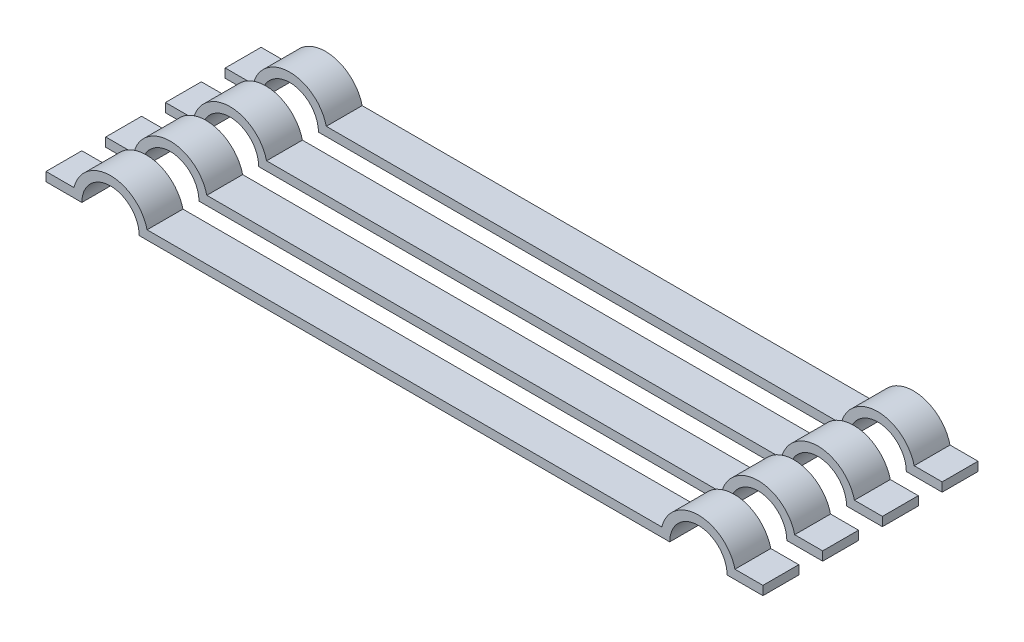
from build123d import *

# Parameters (mm, degrees)
EXTRUDE_THIN1_DEPTH = 6
SKETCH2_W           = 20
SKETCH2_H           = 0.666666
EXTRUDE1_DEPTH      = 2.05


with BuildPart() as part:
    # Sketch1 → Extrude-Thin1 (new body)
    with BuildSketch(Plane.XY):
        with BuildLine():
            Line((-10, 0), (-9, 0))
            ThreePointArc((-9, 0), (-8.2, 0.8), (-7.4, 0))
            Line((-7.4, 0), (7.4, 0))
            ThreePointArc((7.4, 0), (8.2, 0.8), (9, 0))
            Line((9, 0), (10, 0))
            Line((10, 0), (10, 0.25))
            Line((10, 0.25), (9.219803903, 0.25))
            ThreePointArc((9.219803903, 0.25), (8.2, 1.05), (7.180196097, 0.25))
            Line((7.180196097, 0.25), (-7.180196097, 0.25))
            ThreePointArc((-7.180196097, 0.25), (-8.2, 1.05), (-9.219803903, 0.25))
            Line((-9.219803903, 0.25), (-10, 0.25))
            Line((-10, 0.25), (-10, 0))
        make_face()
    extrude(amount=EXTRUDE_THIN1_DEPTH)

    # Sketch2 → Extrude1 (cut, through all)
    with BuildSketch(Plane(origin=(0, 0, 0), x_dir=(1, 0, 0), z_dir=(0, 1, 0))):
        with Locations((0, -1.333333)):
            Rectangle(SKETCH2_W, SKETCH2_H)
        with Locations((0, -2.999999)):
            Rectangle(SKETCH2_W, SKETCH2_H)
        with Locations((0, -4.666665)):
            Rectangle(SKETCH2_W, SKETCH2_H)
    extrude(amount=EXTRUDE1_DEPTH, mode=Mode.SUBTRACT)


solid = part.part
